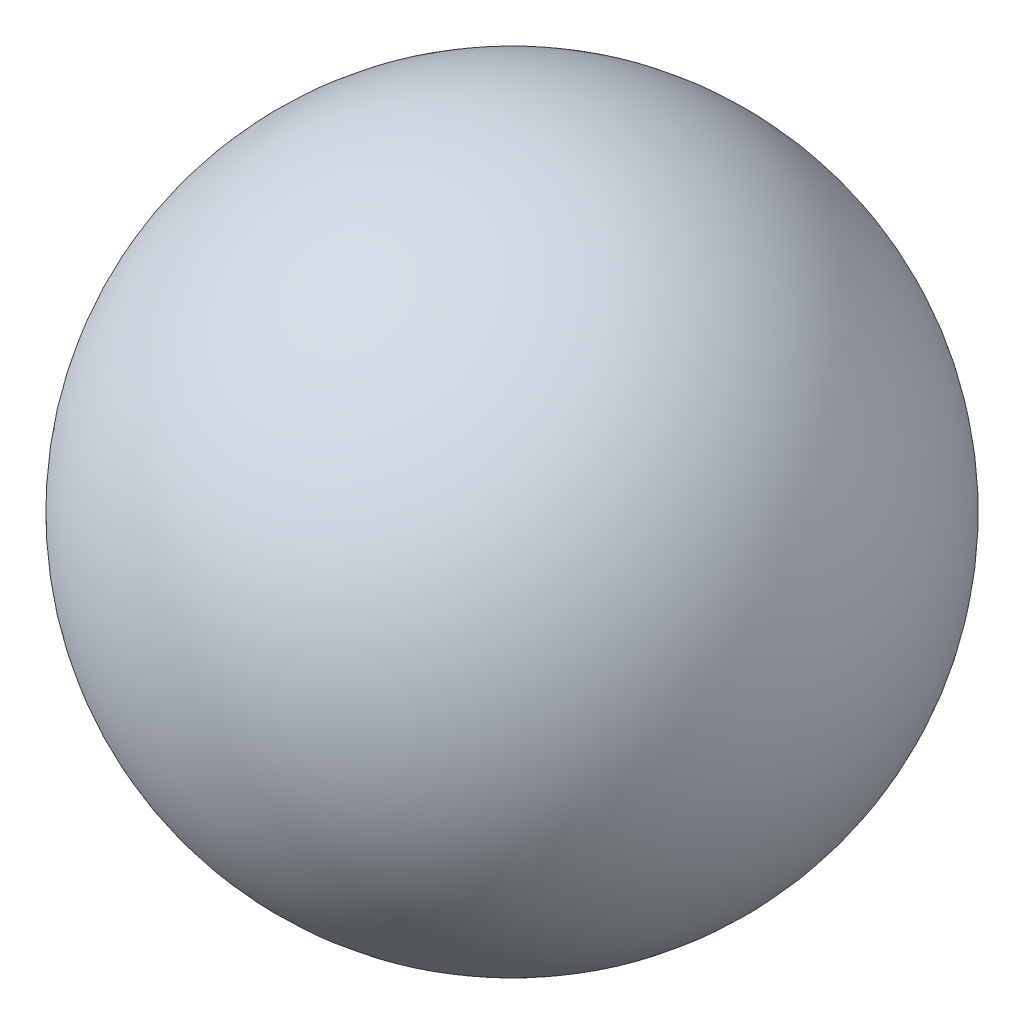
from build123d import *


with BuildPart() as part:
    # Sketch1 → Revolve1 (revolve)
    with BuildSketch(Plane.XY):
        with BuildLine():
            Line((0, 10), (0, -10))
            ThreePointArc((0, -10), (10, 0), (0, 10))
        make_face()
    revolve(axis=Axis((0, 10, 0), (0, -1, 0)))


solid = part.part
